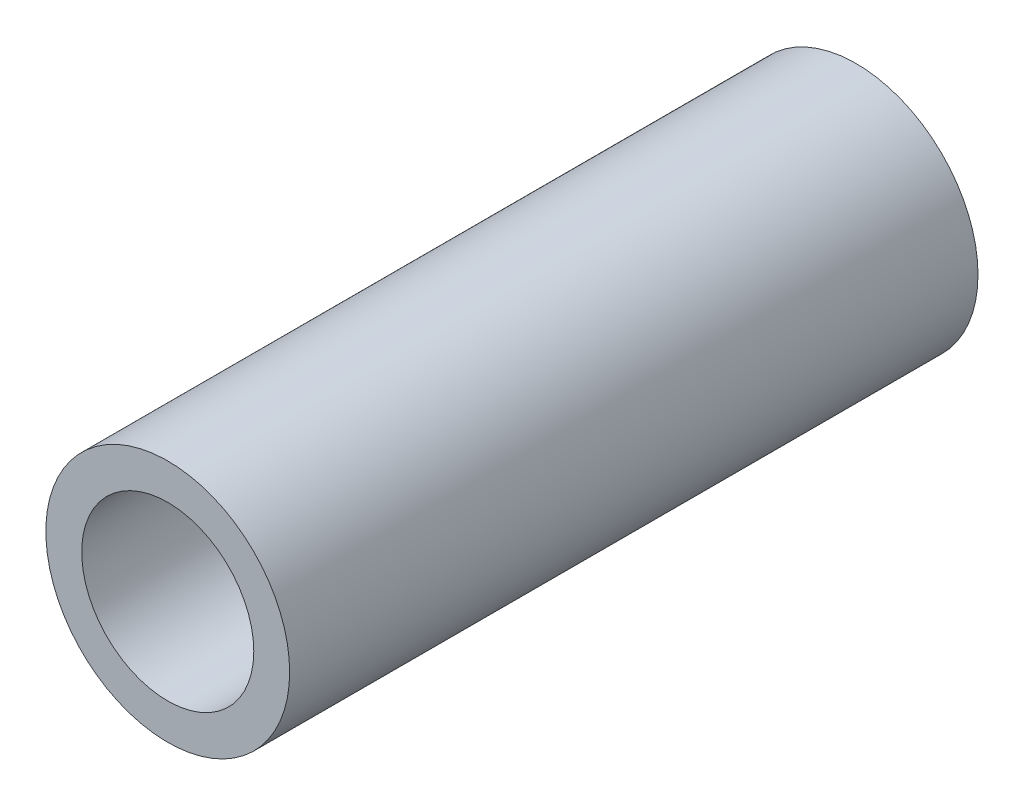
from build123d import *

# Parameters (mm, degrees)
SWEEP1_PROFILE_R     = 13.49375
CUT_SWEEP1_PROFILE_R = 9.525


with BuildPart() as part:
    # Sweep1: sweep along a curve in space
    with BuildLine() as sweep1_path:
        Line((0, 0, 0), (0, 0, 76.2))
    # Sweep1 profile (on start of the path) → Sweep1 (sweep)
    with BuildSketch(Plane.XY):
        Circle(SWEEP1_PROFILE_R)
    sweep(path=sweep1_path.line)

    # Cut-Sweep1: sweep along a curve in space
    with BuildLine() as cut_sweep1_path:
        Line((0, 0, 0), (0, 0, 76.2))
    # Cut-Sweep1 profile (on start of the path) → Cut-Sweep1 (sweep, cut)
    with BuildSketch(Plane.XY):
        Circle(CUT_SWEEP1_PROFILE_R)
    sweep(path=cut_sweep1_path.line, mode=Mode.SUBTRACT)


solid = part.part
